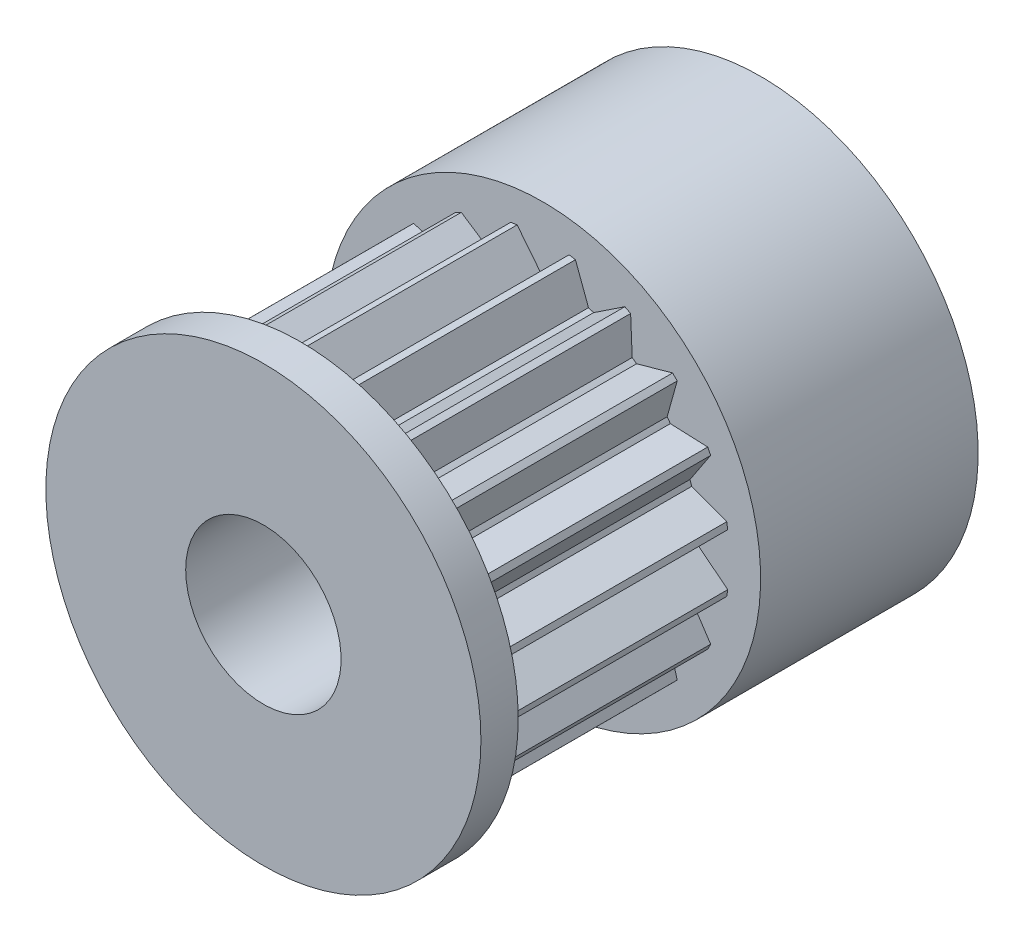
from build123d import *

# Parameters (mm, degrees)
EXTRUDE_1_DEPTH     = 7.8
SKETCH_2_R          = 7
EXTRUDE_2_DEPTH     = 1.2
SKETCH_3_R          = 7
EXTRUDE_3_DEPTH     = 7
SKETCH_4_R          = 2.5
CUT_EXTRUDE_1_DEPTH = 17
SKETCH_6_R          = 2
CUT_EXTRUDE_2_DEPTH = 8
SKETCH_7_R          = 2
CUT_EXTRUDE_3_DEPTH = 8.0000001


with BuildPart() as part:
    # 草图1 → 凸台-拉伸1 (new body)
    with BuildSketch(Plane.XY):
        with BuildLine():
            Line((4.999238476, -0.087262032), (5.941608412, -0.835038606))
            ThreePointArc((5.941608412, -0.835038606), (5.926130044, -0.93860679), (5.908846518, -1.041889066))
            Line((5.908846518, -1.041889066), (4.78152378, -1.461858524))
            ThreePointArc((4.78152378, -1.461858524), (4.755282581, -1.545084972), (4.727592878, -1.627840772))
            Line((4.727592878, -1.627840772), (5.392764278, -2.630226881))
            ThreePointArc((5.392764278, -2.630226881), (5.346039145, -2.723942998), (5.297685557, -2.816829377))
            Line((5.297685557, -2.816829377), (4.095760221, -2.867882182))
            ThreePointArc((4.095760221, -2.867882182), (4.045084972, -2.938926261), (3.99317755, -3.009075116))
            Line((3.99317755, -3.009075116), (4.316038802, -4.167950223))
            ThreePointArc((4.316038802, -4.167950223), (4.242640687, -4.242640687), (4.167950223, -4.316038802))
            Line((4.167950223, -4.316038802), (3.009075116, -3.99317755))
            ThreePointArc((3.009075116, -3.99317755), (2.938926261, -4.045084972), (2.867882182, -4.095760221))
            Line((2.867882182, -4.095760221), (2.816829377, -5.297685557))
            ThreePointArc((2.816829377, -5.297685557), (2.723942998, -5.346039145), (2.630226881, -5.392764278))
            Line((2.630226881, -5.392764278), (1.627840772, -4.727592878))
            ThreePointArc((1.627840772, -4.727592878), (1.545084972, -4.755282581), (1.461858524, -4.78152378))
            Line((1.461858524, -4.78152378), (1.041889066, -5.908846518))
            ThreePointArc((1.041889066, -5.908846518), (0.93860679, -5.926130044), (0.835038606, -5.941608412))
            Line((0.835038606, -5.941608412), (0.087262032, -4.999238476))
            ThreePointArc((0.087262032, -4.999238476), (0, -5), (-0.087262032, -4.999238476))
            Line((-0.087262032, -4.999238476), (-0.835038606, -5.941608412))
            ThreePointArc((-0.835038606, -5.941608412), (-0.93860679, -5.926130044), (-1.041889066, -5.908846518))
            Line((-1.041889066, -5.908846518), (-1.461858524, -4.78152378))
            ThreePointArc((-1.461858524, -4.78152378), (-1.545084972, -4.755282581), (-1.627840772, -4.727592878))
            Line((-1.627840772, -4.727592878), (-2.630226881, -5.392764278))
            ThreePointArc((-2.630226881, -5.392764278), (-2.723942998, -5.346039145), (-2.816829377, -5.297685557))
            Line((-2.816829377, -5.297685557), (-2.867882182, -4.095760221))
            ThreePointArc((-2.867882182, -4.095760221), (-2.938926261, -4.045084972), (-3.009075116, -3.99317755))
            Line((-3.009075116, -3.99317755), (-4.167950223, -4.316038802))
            ThreePointArc((-4.167950223, -4.316038802), (-4.242640687, -4.242640687), (-4.316038802, -4.167950223))
            Line((-4.316038802, -4.167950223), (-3.99317755, -3.009075116))
            ThreePointArc((-3.99317755, -3.009075116), (-4.045084972, -2.938926261), (-4.095760221, -2.867882182))
            Line((-4.095760221, -2.867882182), (-5.297685557, -2.816829377))
            ThreePointArc((-5.297685557, -2.816829377), (-5.346039145, -2.723942998), (-5.392764278, -2.630226881))
            Line((-5.392764278, -2.630226881), (-4.727592878, -1.627840772))
            ThreePointArc((-4.727592878, -1.627840772), (-4.755282581, -1.545084972), (-4.78152378, -1.461858524))
            Line((-4.78152378, -1.461858524), (-5.908846518, -1.041889066))
            ThreePointArc((-5.908846518, -1.041889066), (-5.926130044, -0.93860679), (-5.941608412, -0.835038606))
            Line((-5.941608412, -0.835038606), (-4.999238476, -0.087262032))
            ThreePointArc((-4.999238476, -0.087262032), (-5, 0), (-4.999238476, 0.087262032))
            Line((-4.999238476, 0.087262032), (-5.941608412, 0.835038606))
            ThreePointArc((-5.941608412, 0.835038606), (-5.926130044, 0.93860679), (-5.908846518, 1.041889066))
            Line((-5.908846518, 1.041889066), (-4.78152378, 1.461858524))
            ThreePointArc((-4.78152378, 1.461858524), (-4.755282581, 1.545084972), (-4.727592878, 1.627840772))
            Line((-4.727592878, 1.627840772), (-5.392764278, 2.630226881))
            ThreePointArc((-5.392764278, 2.630226881), (-5.346039145, 2.723942998), (-5.297685557, 2.816829377))
            Line((-5.297685557, 2.816829377), (-4.095760221, 2.867882182))
            ThreePointArc((-4.095760221, 2.867882182), (-4.045084972, 2.938926261), (-3.99317755, 3.009075116))
            Line((-3.99317755, 3.009075116), (-4.316038802, 4.167950223))
            ThreePointArc((-4.316038802, 4.167950223), (-4.242640687, 4.242640687), (-4.167950223, 4.316038802))
            Line((-4.167950223, 4.316038802), (-3.009075116, 3.99317755))
            ThreePointArc((-3.009075116, 3.99317755), (-2.938926261, 4.045084972), (-2.867882182, 4.095760221))
            Line((-2.867882182, 4.095760221), (-2.816829377, 5.297685557))
            ThreePointArc((-2.816829377, 5.297685557), (-2.723942998, 5.346039145), (-2.630226881, 5.392764278))
            Line((-2.630226881, 5.392764278), (-1.627840772, 4.727592878))
            ThreePointArc((-1.627840772, 4.727592878), (-1.545084972, 4.755282581), (-1.461858524, 4.78152378))
            Line((-1.461858524, 4.78152378), (-1.041889066, 5.908846518))
            ThreePointArc((-1.041889066, 5.908846518), (-0.93860679, 5.926130044), (-0.835038606, 5.941608412))
            Line((-0.835038606, 5.941608412), (-0.087262032, 4.999238476))
            ThreePointArc((-0.087262032, 4.999238476), (0, 5), (0.087262032, 4.999238476))
            Line((0.087262032, 4.999238476), (0.835038606, 5.941608412))
            ThreePointArc((0.835038606, 5.941608412), (0.93860679, 5.926130044), (1.041889066, 5.908846518))
            Line((1.041889066, 5.908846518), (1.461858524, 4.78152378))
            ThreePointArc((1.461858524, 4.78152378), (1.545084972, 4.755282581), (1.627840772, 4.727592878))
            Line((1.627840772, 4.727592878), (2.630226881, 5.392764278))
            ThreePointArc((2.630226881, 5.392764278), (2.723942998, 5.346039145), (2.816829377, 5.297685557))
            Line((2.816829377, 5.297685557), (2.867882182, 4.095760221))
            ThreePointArc((2.867882182, 4.095760221), (2.938926261, 4.045084972), (3.009075116, 3.99317755))
            Line((3.009075116, 3.99317755), (4.167950223, 4.316038802))
            ThreePointArc((4.167950223, 4.316038802), (4.242640687, 4.242640687), (4.316038802, 4.167950223))
            Line((4.316038802, 4.167950223), (3.99317755, 3.009075116))
            ThreePointArc((3.99317755, 3.009075116), (4.045084972, 2.938926261), (4.095760221, 2.867882182))
            Line((4.095760221, 2.867882182), (5.297685557, 2.816829377))
            ThreePointArc((5.297685557, 2.816829377), (5.346039145, 2.723942998), (5.392764278, 2.630226881))
            Line((5.392764278, 2.630226881), (4.727592878, 1.627840772))
            ThreePointArc((4.727592878, 1.627840772), (4.755282581, 1.545084972), (4.78152378, 1.461858524))
            Line((4.78152378, 1.461858524), (5.908846518, 1.041889066))
            ThreePointArc((5.908846518, 1.041889066), (5.926130044, 0.93860679), (5.941608412, 0.835038606))
            Line((5.941608412, 0.835038606), (4.999238476, 0.087262032))
            ThreePointArc((4.999238476, 0.087262032), (5, 0), (4.999238476, -0.087262032))
        make_face()
    extrude(amount=EXTRUDE_1_DEPTH)

    # 草图2 → 凸台-拉伸2 (add)
    with BuildSketch(Plane.XY.offset(7.8)):
        Circle(SKETCH_2_R)
    extrude(amount=EXTRUDE_2_DEPTH)

    # 草图3 → 凸台-拉伸3 (add)
    with BuildSketch(Plane(origin=(0, 0, 0), x_dir=(-1, 0, 0), z_dir=(0, 0, -1))):
        Circle(SKETCH_3_R)
    extrude(amount=EXTRUDE_3_DEPTH)

    # 草图4 → 切除-拉伸1 (cut, through all)
    with BuildSketch(Plane(origin=(0, 0, -7), x_dir=(-1, 0, 0), z_dir=(0, 0, -1))):
        Circle(SKETCH_4_R)
    extrude(amount=-CUT_EXTRUDE_1_DEPTH, mode=Mode.SUBTRACT)

    # 草图6 → 切除-拉伸2 (cut, through all)
    with BuildSketch(Plane(origin=(0, 0, 0), x_dir=(1, 0, 0), z_dir=(0, 1, 0))):
        with Locations((0, 3.5)):
            Circle(SKETCH_6_R)
    extrude(amount=-CUT_EXTRUDE_2_DEPTH, mode=Mode.SUBTRACT)

    # 草图7 → 切除-拉伸3 (cut, through all)
    with BuildSketch(Plane(origin=(0, 0, 0), x_dir=(0, 0, -1), z_dir=(1, 0, 0))):
        with Locations((3.5, 0)):
            Circle(SKETCH_7_R)
    extrude(amount=-CUT_EXTRUDE_3_DEPTH, mode=Mode.SUBTRACT)


solid = part.part
